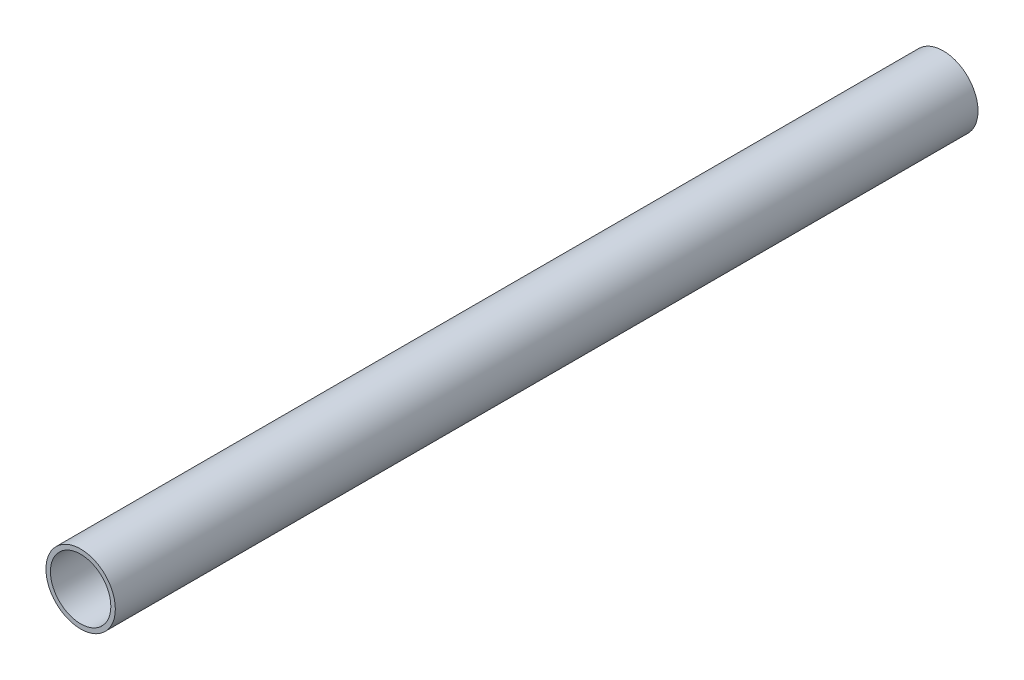
from build123d import *

# Parameters (mm, degrees)
SKETCH1_R           = 30.1625
SKETCH1_R_2         = 26.2509
EXTRUDE_THIN1_DEPTH = 375


with BuildPart() as part:
    # Sketch1 → Extrude-Thin1 (new body, symmetric)
    with BuildSketch(Plane.XY):
        Circle(SKETCH1_R)
        Circle(SKETCH1_R_2, mode=Mode.SUBTRACT)
    extrude(amount=EXTRUDE_THIN1_DEPTH, both=True)


solid = part.part
